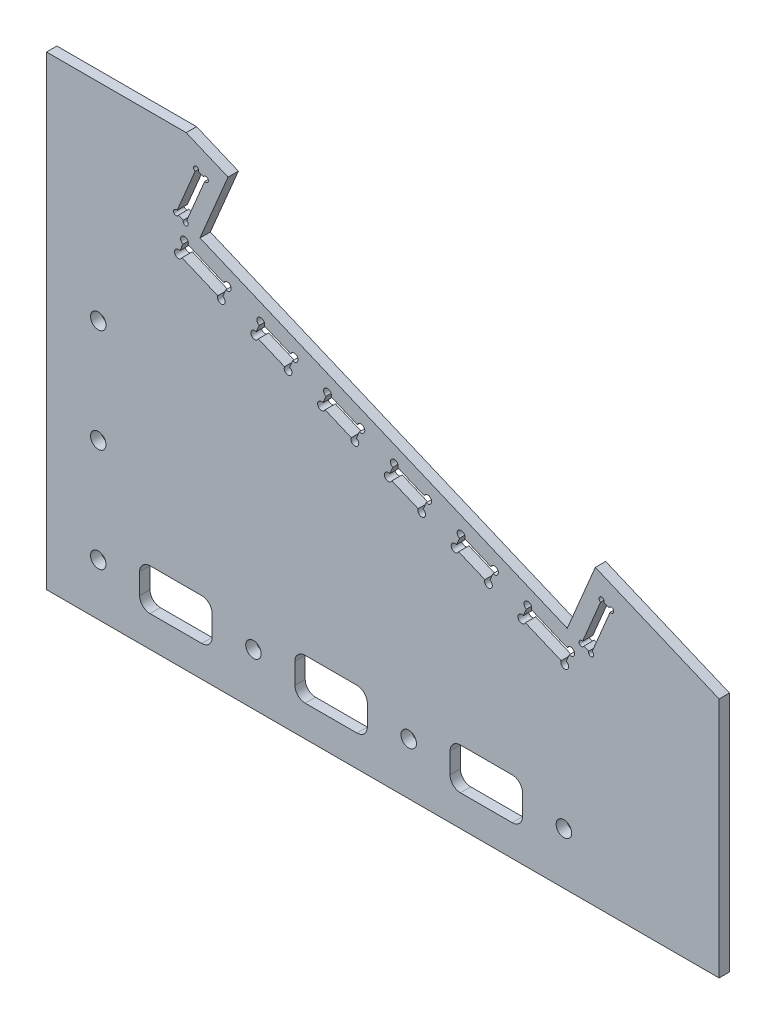
from build123d import *

# Parameters (mm, degrees)
SKETCH_1_W          = 130
SKETCH_1_H          = 90
SKETCH_1_R          = 1.5
EXTRUDE_1_DEPTH     = 2
CUT_EXTRUDE_1_DEPTH = 3
CUT_EXTRUDE_2_DEPTH = 3
CUT_EXTRUDE_3_DEPTH = 3
SKETCH_6_R          = 0.75
SKETCH_6_R_2        = 0.5
CUT_EXTRUDE_5_DEPTH = 10
CUT_EXTRUDE_7_DEPTH = 3


with BuildPart() as part:
    # 草图1 → 凸台-拉伸1 (new body)
    with BuildSketch(Plane.XY):
        with Locations((65, 45)):
            Rectangle(SKETCH_1_W, SKETCH_1_H)
        with Locations((10, 10)):
            Circle(SKETCH_1_R, mode=Mode.SUBTRACT)
        with Locations((10, 30)):
            Circle(SKETCH_1_R, mode=Mode.SUBTRACT)
        with Locations((10, 50)):
            Circle(SKETCH_1_R, mode=Mode.SUBTRACT)
        with Locations((40, 10)):
            Circle(SKETCH_1_R, mode=Mode.SUBTRACT)
        with Locations((70, 10)):
            Circle(SKETCH_1_R, mode=Mode.SUBTRACT)
        with Locations((100, 10)):
            Circle(SKETCH_1_R, mode=Mode.SUBTRACT)
    extrude(amount=EXTRUDE_1_DEPTH)

    # 草图2 → 切除-拉伸1 (cut, through all)
    with BuildSketch(Plane.XY.offset(2)):
        Polygon((27, 90), (130, 46.702786812), (130, 90), align=None)
    extrude(amount=-CUT_EXTRUDE_1_DEPTH, mode=Mode.SUBTRACT)

    # 草图3 → 切除-拉伸2 (cut, through all)
    with BuildSketch(Plane.XY.offset(2)):
        Polygon((35.084739839, 86.601488307), (106.068202512, 56.76278815), (100.642984301, 43.856704028), (29.659521629, 73.695404185), align=None)
    extrude(amount=-CUT_EXTRUDE_2_DEPTH, mode=Mode.SUBTRACT)

    # 草图4 → 切除-拉伸3 (cut, through all)
    with BuildSketch(Plane.XY.offset(2)):
        Polygon((30.769088039, 84.07658246), (26.893932174, 74.857950944), (25.04098724, 75.636857273), (28.916143104, 84.855488789), align=None)
        Polygon((107.283729621, 51.912788784), (103.408573756, 42.694157268), (105.252300059, 41.919126096), (109.127455924, 51.137757611), align=None)
        Polygon((26.653248567, 71.704845903), (34.950016931, 68.217205625), (33.787470172, 65.45161617), (25.490701807, 68.939256448), align=None)
        Polygon((41.403058992, 65.504596519), (47.856101053, 62.791987414), (46.693554294, 60.02639796), (40.240512233, 62.739007065), align=None)
        Polygon((80.121311359, 49.228941888), (86.57435342, 46.516332783), (85.41180666, 43.750743329), (78.958764599, 46.463352434), align=None)
        Polygon((93.027395481, 43.803723678), (101.324163845, 40.3160834), (100.161617086, 37.550493945), (91.864848722, 41.038134223), align=None)
        Polygon((54.309143114, 60.079378309), (60.762185175, 57.366769204), (59.599638416, 54.601179749), (53.146596355, 57.313788854), align=None)
        Polygon((67.215227236, 54.654160099), (73.668269298, 51.941550994), (72.505722538, 49.175961539), (66.052680477, 51.888570644), align=None)
    extrude(amount=-CUT_EXTRUDE_3_DEPTH, mode=Mode.SUBTRACT)

    # 草图6 → 切除-拉伸5 (cut)
    with BuildSketch(Plane.XY.offset(2)):
        with Locations((25.490701807, 68.939256448)):
            Circle(SKETCH_6_R)
        with Locations((26.653248567, 71.704845903)):
            Circle(SKETCH_6_R)
        with Locations((34.950016931, 68.217205625)):
            Circle(SKETCH_6_R)
        with Locations((33.787470172, 65.45161617)):
            Circle(SKETCH_6_R)
        with Locations((46.693554294, 60.02639796)):
            Circle(SKETCH_6_R)
        with Locations((40.240512233, 62.739007065)):
            Circle(SKETCH_6_R)
        with Locations((41.403058992, 65.504596519)):
            Circle(SKETCH_6_R)
        with Locations((47.856101053, 62.791987414)):
            Circle(SKETCH_6_R)
        with Locations((80.121311359, 49.228941888)):
            Circle(SKETCH_6_R)
        with Locations((78.958764599, 46.463352434)):
            Circle(SKETCH_6_R)
        with Locations((85.41180666, 43.750743329)):
            Circle(SKETCH_6_R)
        with Locations((86.57435342, 46.516332783)):
            Circle(SKETCH_6_R)
        with Locations((100.161617086, 37.550493945)):
            Circle(SKETCH_6_R)
        with Locations((101.324163845, 40.3160834)):
            Circle(SKETCH_6_R)
        with Locations((93.027395481, 43.803723678)):
            Circle(SKETCH_6_R)
        with Locations((91.864848722, 41.038134223)):
            Circle(SKETCH_6_R)
        with Locations((26.893932174, 74.857950944)):
            Circle(SKETCH_6_R_2)
        with Locations((25.04098724, 75.636857273)):
            Circle(SKETCH_6_R_2)
        with Locations((28.916143104, 84.855488789)):
            Circle(SKETCH_6_R_2)
        with Locations((30.769088039, 84.07658246)):
            Circle(SKETCH_6_R_2)
        with Locations((105.252300059, 41.919126096)):
            Circle(SKETCH_6_R_2)
        with Locations((103.408573756, 42.694157268)):
            Circle(SKETCH_6_R_2)
        with Locations((107.283729621, 51.912788784)):
            Circle(SKETCH_6_R_2)
        with Locations((109.127455924, 51.137757611)):
            Circle(SKETCH_6_R_2)
        with Locations((54.309143114, 60.079378309)):
            Circle(SKETCH_6_R)
        with Locations((60.762185175, 57.366769204)):
            Circle(SKETCH_6_R)
        with Locations((53.146596355, 57.313788854)):
            Circle(SKETCH_6_R)
        with Locations((59.599638416, 54.601179749)):
            Circle(SKETCH_6_R)
        with Locations((67.215227236, 54.654160099)):
            Circle(SKETCH_6_R)
        with Locations((73.668269298, 51.941550994)):
            Circle(SKETCH_6_R)
        with Locations((72.505722538, 49.175961539)):
            Circle(SKETCH_6_R)
        with Locations((66.052680477, 51.888570644)):
            Circle(SKETCH_6_R)
    extrude(amount=-CUT_EXTRUDE_5_DEPTH, mode=Mode.SUBTRACT)

    # 草图8 → 切除-拉伸7 (cut, through all)
    with BuildSketch(Plane(origin=(0, 0, 0), x_dir=(-1, 0, 0), z_dir=(0, 0, -1))):
        with BuildLine():
            Line((-90, 14), (-80, 14))
            ThreePointArc((-80, 14), (-78.585786438, 13.414213562), (-78, 12))
            Line((-78, 12), (-78, 8))
            ThreePointArc((-78, 8), (-78.585786438, 6.585786438), (-80, 6))
            Line((-80, 6), (-90, 6))
            ThreePointArc((-90, 6), (-91.414213562, 6.585786438), (-92, 8))
            Line((-92, 8), (-92, 12))
            ThreePointArc((-92, 12), (-91.414213562, 13.414213562), (-90, 14))
        make_face()
        with BuildLine():
            Line((-62, 8), (-62, 12))
            ThreePointArc((-62, 12), (-61.414213562, 13.414213562), (-60, 14))
            Line((-60, 14), (-50, 14))
            ThreePointArc((-50, 14), (-48.585786438, 13.414213562), (-48, 12))
            Line((-48, 12), (-48, 8))
            ThreePointArc((-48, 8), (-48.585786438, 6.585786438), (-50, 6))
            Line((-50, 6), (-60, 6))
            ThreePointArc((-60, 6), (-61.414213562, 6.585786438), (-62, 8))
        make_face()
        with BuildLine():
            Line((-30, 14), (-20, 14))
            ThreePointArc((-20, 14), (-18.585786438, 13.414213562), (-18, 12))
            Line((-18, 12), (-18, 8))
            ThreePointArc((-18, 8), (-18.585786438, 6.585786438), (-20, 6))
            Line((-20, 6), (-30, 6))
            ThreePointArc((-30, 6), (-31.414213562, 6.585786438), (-32, 8))
            Line((-32, 8), (-32, 12))
            ThreePointArc((-32, 12), (-31.414213562, 13.414213562), (-30, 14))
        make_face()
    extrude(amount=-CUT_EXTRUDE_7_DEPTH, mode=Mode.SUBTRACT)


solid = part.part
